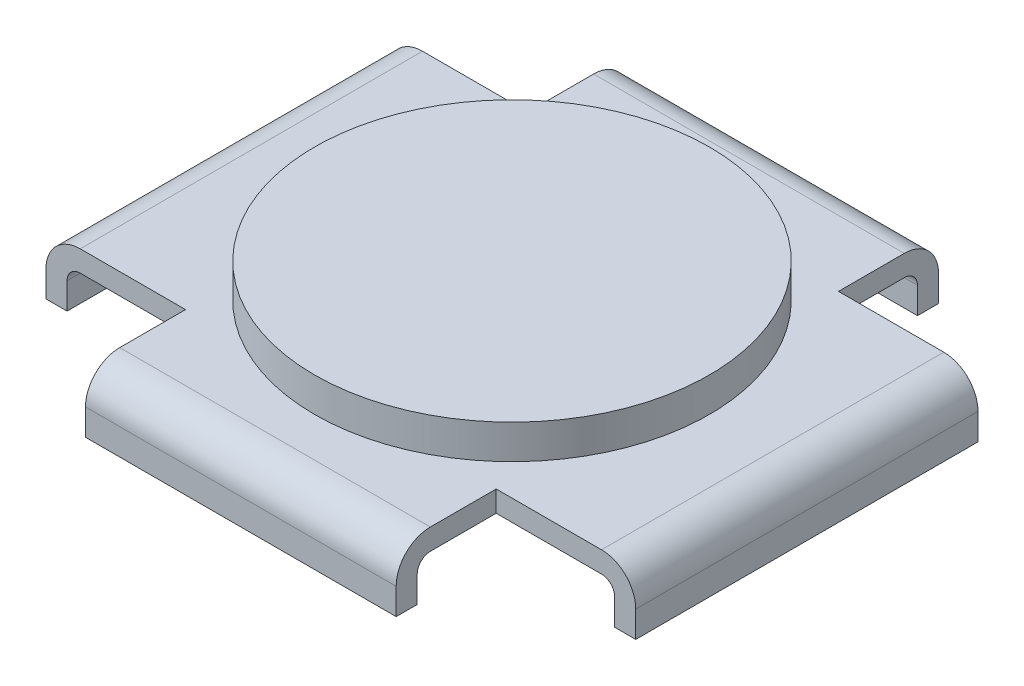
from build123d import *

# Parameters (mm, degrees)
SKETCH_1_W          = 44.8
SKETCH_1_H          = 41.2
EXTRUDE_1_DEPTH     = 4.6
SKETCH_3_W          = 41.6
SKETCH_3_H          = 38
CUT_EXTRUDE_1_DEPTH = 3
SKETCH_4_W          = 10.6
SKETCH_4_H          = 7.6
CUT_EXTRUDE_2_DEPTH = 5.6
FILLET_1_R          = 2.6
FILLET_2_R          = 1
SKETCH_5_R          = 15
EXTRUDE_2_DEPTH     = 2.6


with BuildPart() as part:
    # ｽｹｯﾁ1 → ﾎﾞｽ - 押し出し1 (new body)
    with BuildSketch(Plane(origin=(0, 0, 0), x_dir=(1, 0, 0), z_dir=(0, 1, 0))):
        Rectangle(SKETCH_1_W, SKETCH_1_H)
    extrude(amount=EXTRUDE_1_DEPTH)

    # ｽｹｯﾁ3 → ｶｯﾄ - 押し出し1 (cut)
    with BuildSketch(Plane(origin=(0, 0, 0), x_dir=(-1, 0, 0), z_dir=(0, -1, 0))):
        Rectangle(SKETCH_3_W, SKETCH_3_H)
    extrude(amount=-CUT_EXTRUDE_1_DEPTH, mode=Mode.SUBTRACT)

    # ｽｹｯﾁ4 → ｶｯﾄ - 押し出し2 (cut, through all)
    with BuildSketch(Plane(origin=(0, 4.6, 0), x_dir=(1, 0, 0), z_dir=(0, 1, 0))):
        with Locations((17.1, -16.8)):
            Rectangle(SKETCH_4_W, SKETCH_4_H)
        with Locations((17.1, 16.8)):
            Rectangle(SKETCH_4_W, SKETCH_4_H)
        with Locations((-17.1, -16.8)):
            Rectangle(SKETCH_4_W, SKETCH_4_H)
        with Locations((-17.1, 16.8)):
            Rectangle(SKETCH_4_W, SKETCH_4_H)
    extrude(amount=-CUT_EXTRUDE_2_DEPTH, mode=Mode.SUBTRACT)

    # ﾌｨﾚｯﾄ1
    fillet_1_edges = [part.edges().sort_by_distance(p)[0] for p in [
        (22.4, 4.6, 0),
        (0, 4.6, -20.6),
        (0, 4.6, 20.6),
        (-22.4, 4.6, 0),
    ]]
    fillet(fillet_1_edges, radius=FILLET_1_R)

    # ﾌｨﾚｯﾄ2
    fillet_2_edges = [part.edges().sort_by_distance(p)[0] for p in [
        (0, 3, 19),
        (20.8, 3, 0),
        (-20.8, 3, 0),
        (0, 3, -19),
    ]]
    fillet(fillet_2_edges, radius=FILLET_2_R)

    # ｽｹｯﾁ5 → ﾎﾞｽ - 押し出し2 (add)
    with BuildSketch(Plane(origin=(0, 4.6, 0), x_dir=(1, 0, 0), z_dir=(0, 1, 0))):
        Circle(SKETCH_5_R)
    extrude(amount=EXTRUDE_2_DEPTH)


solid = part.part
